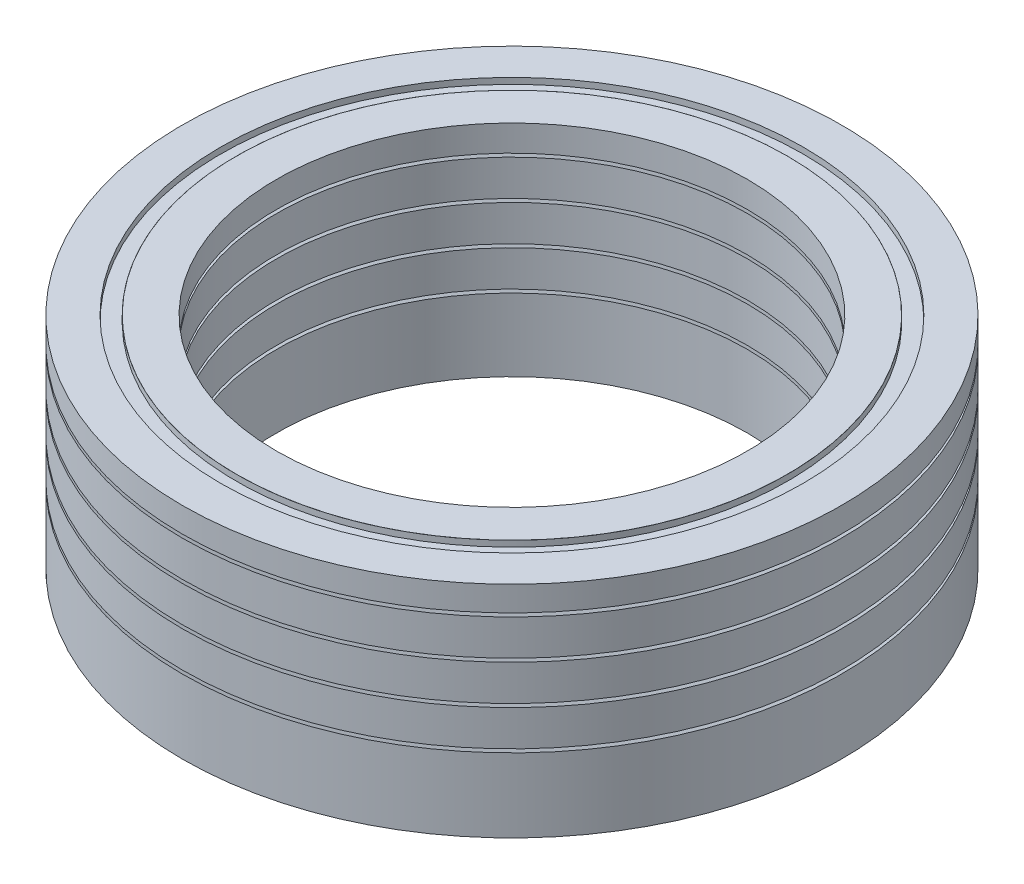
from build123d import *

# Parameters (mm, degrees)
SKETCH1_R          = 21
EXTRUDE1_DEPTH     = 14
SKETCH2_R          = 15
CUT_EXTRUDE1_DEPTH = 14


with BuildPart() as part:
    # Sketch1 → Extrude1 (new body)
    with BuildSketch(Plane(origin=(0, 0, 0), x_dir=(1, 0, 0), z_dir=(0, 1, 0))):
        Circle(SKETCH1_R)
    extrude(amount=EXTRUDE1_DEPTH)

    # Sketch2 → Cut-Extrude1 (cut)
    with BuildSketch(Plane(origin=(0, 0, 0), x_dir=(1, 0, 0), z_dir=(0, 1, 0))):
        Circle(SKETCH2_R)
    extrude(amount=CUT_EXTRUDE1_DEPTH, mode=Mode.SUBTRACT)

    # Sketch3 → Cut-Revolve1 (revolve, cut)
    with BuildSketch(Plane(origin=(0, 0, 0), x_dir=(0, 0, -1), z_dir=(1, 0, 0))):
        Polygon((-21.299772173, 12.561584254), (-18.05634917, 11), (-14.216551494, 12.677581509), (-14.216551494, 12.459327008), (-17.560398762, 10.998422863), (-17.560398762, 10.613964891), (-18.560398762, 10.613964891), (-18.560398762, 11.020707157), (-21.299772173, 12.339610791), (-21.299772173, 10.061584254), (-18.05634917, 8.5), (-14.216551494, 10.177581509), (-14.216551494, 9.959327008), (-17.560398762, 8.498422863), (-17.560398762, 8.113964891), (-18.560398762, 8.113964891), (-18.560398762, 8.520707157), (-21.299772173, 9.839610791), (-21.299772173, 7.561584254), (-18.05634917, 6), (-14.216551494, 7.677581509), (-14.216551494, 7.459327008), (-17.560398762, 5.998422863), (-17.560398762, 5.613964891), (-18.560398762, 5.613964891), (-18.560398762, 6.020707157), (-21.299772173, 7.339610791), (-21.299772173, 5.061584254), (-18.05634917, 3.5), (-14.216551494, 5.177581509), (-14.216551494, 4.959327008), (-17.560398762, 3.498422863), (-17.560398762, 3.113964891), (-18.560398762, 3.113964891), (-18.560398762, 3.520707157), (-21.299772173, 4.839610791), (-21.299772173, 4.44987318), (-21.954239637, 4.44987318), (-21.954239637, 16.757816968), (-21.299772173, 16.757816968), (-21.299772173, 15.677581509), (-14.216551494, 15.677581509), (-14.216551494, 15.459327008), (-17.560398762, 13.998422863), (-17.560398762, 13.613964891), (-18.560398762, 13.613964891), (-18.560398762, 14.020707157), (-21.299772173, 15.339610791), align=None)
    revolve(axis=Axis((0, 0, 0), (0, 1, 0)), mode=Mode.SUBTRACT)


with BuildPart() as cut_revolve1_piece_1:
    # of the separate pieces the step leaves, piece 1, a body of its own (cut_revolve1_pieces)
    add(part.part.solids().sort_by_distance((21, 0, 0))[0])


with BuildPart() as cut_revolve1_piece_2:
    # of the separate pieces the step leaves, piece 2, a body of its own (cut_revolve1_pieces)
    add(part.part.solids().sort_by_distance((0, 12.417255406, 21))[0])


with BuildPart() as cut_revolve1_piece_3:
    # of the separate pieces the step leaves, piece 3, a body of its own (cut_revolve1_pieces)
    add(part.part.solids().sort_by_distance((0, 9.917255406, 21))[0])


with BuildPart() as cut_revolve1_piece_4:
    # of the separate pieces the step leaves, piece 4, a body of its own (cut_revolve1_pieces)
    add(part.part.solids().sort_by_distance((0, 4.917255406, 21))[0])


with BuildPart() as cut_revolve1_piece_5:
    # of the separate pieces the step leaves, piece 5, a body of its own (cut_revolve1_pieces)
    add(part.part.solids().sort_by_distance((0, 7.417255406, 21))[0])


solid = Compound([cut_revolve1_piece_1.part, cut_revolve1_piece_2.part, cut_revolve1_piece_3.part, cut_revolve1_piece_4.part, cut_revolve1_piece_5.part])
